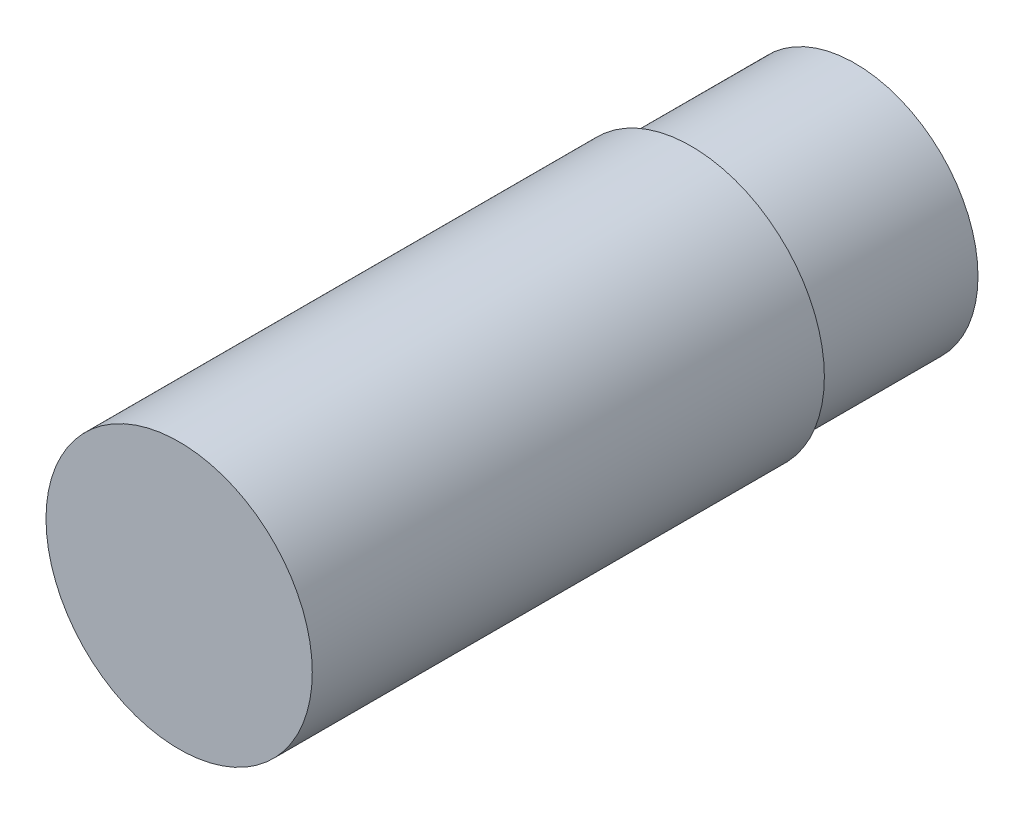
from build123d import *

# Parameters (mm, degrees)
SKETCH1_R           = 1.524
BOSS_EXTRUDE1_DEPTH = 2.032
SKETCH2_R           = 1.651
BOSS_EXTRUDE2_DEPTH = 6.35


with BuildPart() as part:
    # Sketch1 → Boss-Extrude1 (new body)
    with BuildSketch(Plane.XY):
        Circle(SKETCH1_R)
    extrude(amount=BOSS_EXTRUDE1_DEPTH)

    # Sketch2 → Boss-Extrude2 (add)
    with BuildSketch(Plane.XY.offset(2.032)):
        Circle(SKETCH2_R)
    extrude(amount=BOSS_EXTRUDE2_DEPTH)


solid = part.part
